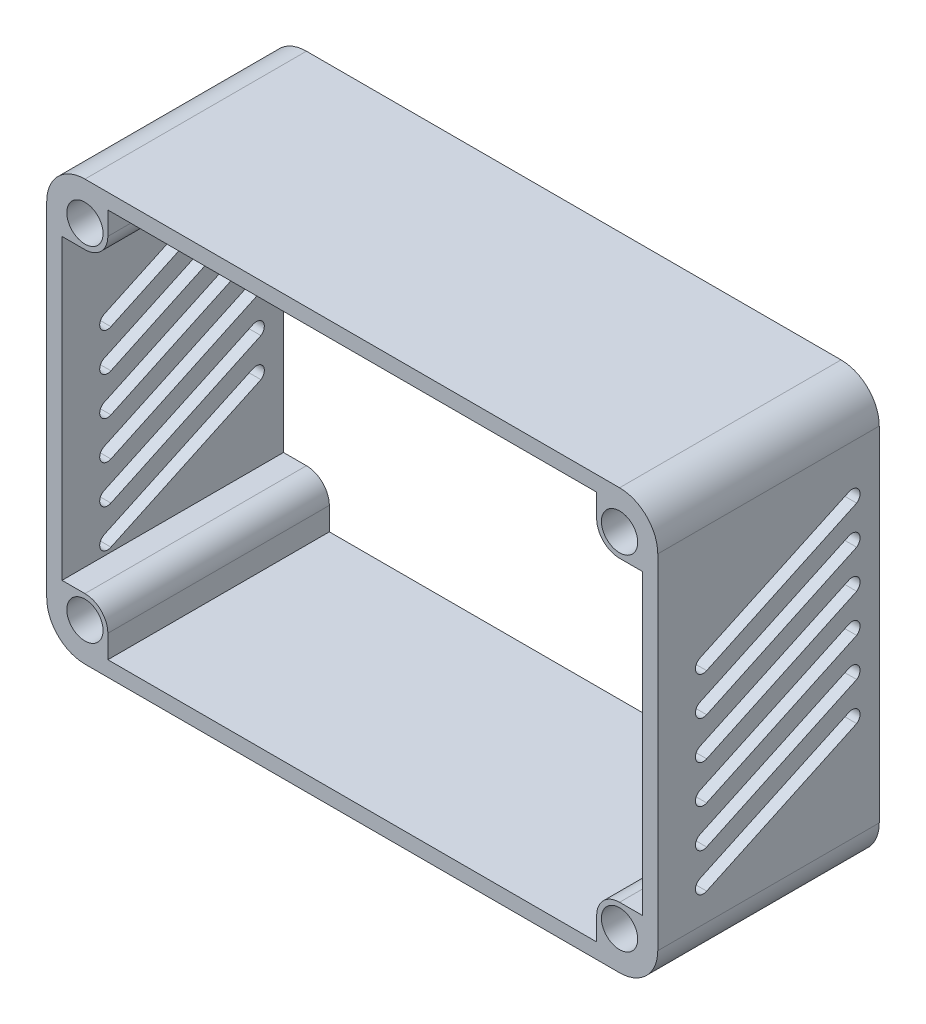
from build123d import *

# Parameters (mm, degrees)
SKETCH_1_R             = 4.75
EXTRUDE_1_DEPTH        = 58
CUT_EXTRUDE_1_DEPTH    = 169
PATTERN_LINEAR_1_COUNT = 6
PATTERN_LINEAR_1_PITCH = 10


with BuildPart() as part:
    # Эскиз1 → Бобышка-Вытянуть1 (new body)
    with BuildSketch(Plane.XY):
        with BuildLine():
            Line((-70, 55), (70, 55))
            ThreePointArc((70, 55), (77.071067812, 52.071067812), (80, 45))
            Line((80, 45), (80, -45))
            ThreePointArc((80, -45), (77.071067812, -52.071067812), (70, -55))
            Line((70, -55), (-70, -55))
            ThreePointArc((-70, -55), (-77.071067812, -52.071067812), (-80, -45))
            Line((-80, -45), (-80, 45))
            ThreePointArc((-80, 45), (-77.071067812, 52.071067812), (-70, 55))
        make_face()
        with Locations((70, 45)):
            Circle(SKETCH_1_R, mode=Mode.SUBTRACT)
        with Locations((70, -45)):
            Circle(SKETCH_1_R, mode=Mode.SUBTRACT)
        with Locations((-70, -45)):
            Circle(SKETCH_1_R, mode=Mode.SUBTRACT)
        with Locations((-70, 45)):
            Circle(SKETCH_1_R, mode=Mode.SUBTRACT)
        with BuildLine():
            Line((-64, 51), (64, 51))
            Line((64, 51), (64, 45))
            ThreePointArc((64, 45), (65.757359313, 40.757359313), (70, 39))
            Line((70, 39), (76, 39))
            Line((76, 39), (76, -39))
            Line((76, -39), (70, -39))
            ThreePointArc((70, -39), (65.757359313, -40.757359313), (64, -45))
            Line((64, -45), (64, -51))
            Line((64, -51), (-64, -51))
            Line((-64, -51), (-64, -45))
            ThreePointArc((-64, -45), (-65.757359313, -40.757359313), (-70, -39))
            Line((-70, -39), (-76, -39))
            Line((-76, -39), (-76, 39))
            Line((-76, 39), (-70, 39))
            ThreePointArc((-70, 39), (-65.757359313, 40.757359313), (-64, 45))
            Line((-64, 45), (-64, 51))
        make_face(mode=Mode.SUBTRACT)
    extrude(amount=EXTRUDE_1_DEPTH)

    # Эскиз2 → Вырез-Вытянуть1 (cut)
    with BuildSketch(Plane.ZY.offset(80)):
        with BuildLine():
            Line((46.937976774, 15.864192118), (8.050346324, 33.995467526))
            ThreePointArc((8.050346324, 33.995467526), (5.329053146, 33.235382363), (5.916242197, 30.471621333))
            Line((5.916242197, 30.471621333), (45.193454902, 12.123052891))
            ThreePointArc((45.193454902, 12.123052891), (47.936328276, 13.121453414), (46.937976774, 15.864192118))
        make_face()
    cut_extrude_1 = extrude(amount=-CUT_EXTRUDE_1_DEPTH, mode=Mode.SUBTRACT)

    # Линейный массив1: Вырез-Вытянуть1 ×6
    with Locations(*[(0, -i * PATTERN_LINEAR_1_PITCH, 0) for i in range(1, PATTERN_LINEAR_1_COUNT)]):
        add(cut_extrude_1, mode=Mode.SUBTRACT)


solid = part.part
